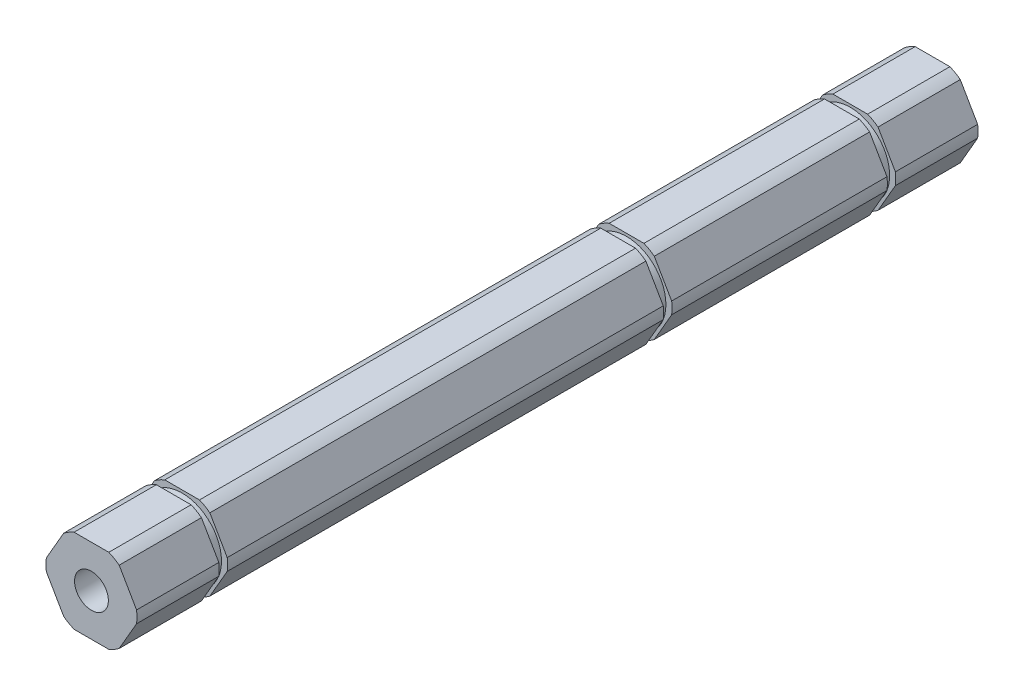
from build123d import *

# Parameters (mm, degrees)
BOSS_EXTRUDE1_DEPTH            = 32.512
SKETCH2_R                      = 5.9436
BOSS_EXTRUDE2_DEPTH            = 1.27
SKETCH3_R                      = 5.9436
BOSS_EXTRUDE3_DEPTH            = 1.27
BOSS_EXTRUDE4_DEPTH            = 65.8368
BOSS_EXTRUDE5_DEPTH            = 12.4206
SKETCH6_R                      = 5.9436
BOSS_EXTRUDE6_DEPTH            = 1.27
BOSS_EXTRUDE7_DEPTH            = 12.4206
F_7_0_201_DIAMETER_HOLE1_D     = 5.1054
F_7_0_201_DIAMETER_HOLE1_DEPTH = 127


with BuildPart() as part:
    # Sketch1 → Boss-Extrude1 (new body)
    with BuildSketch(Plane.XY.offset(-17.2974)):
        with BuildLine():
            Line((-4.187390656, 5.447226632), (-6.811131972, 0.902773368))
            ThreePointArc((-6.811131972, 0.902773368), (-6.8707, 0), (-6.811131972, -0.902773368))
            Line((-6.811131972, -0.902773368), (-4.187390656, -5.447226632))
            ThreePointArc((-4.187390656, -5.447226632), (-3.43535, -5.950200742), (-2.623741315, -6.35))
            Line((-2.623741315, -6.35), (2.623741315, -6.35))
            ThreePointArc((2.623741315, -6.35), (3.43535, -5.950200742), (4.187390656, -5.447226632))
            Line((4.187390656, -5.447226632), (6.811131972, -0.902773368))
            ThreePointArc((6.811131972, -0.902773368), (6.8707, 0), (6.811131972, 0.902773368))
            Line((6.811131972, 0.902773368), (4.187390656, 5.447226632))
            ThreePointArc((4.187390656, 5.447226632), (3.43535, 5.950200742), (2.623741315, 6.35))
            Line((2.623741315, 6.35), (-2.623741315, 6.35))
            ThreePointArc((-2.623741315, 6.35), (-3.43535, 5.950200742), (-4.187390656, 5.447226632))
        make_face()
    extrude(amount=-BOSS_EXTRUDE1_DEPTH)

    # Sketch2 → Boss-Extrude2 (add)
    with BuildSketch(Plane(origin=(0, 0, -49.8094), x_dir=(-1, 0, 0), z_dir=(0, 0, -1))):
        Circle(SKETCH2_R)
    extrude(amount=BOSS_EXTRUDE2_DEPTH)

    # Sketch3 → Boss-Extrude3 (add)
    with BuildSketch(Plane.XY.offset(-17.2974)):
        Circle(SKETCH3_R)
    extrude(amount=BOSS_EXTRUDE3_DEPTH)

    # Sketch4 → Boss-Extrude4 (add)
    with BuildSketch(Plane(origin=(0, 0, -16.0274), x_dir=(-1, 0, 0), z_dir=(0, 0, -1))):
        with BuildLine():
            Line((2.623741315, 6.35), (-2.623741315, 6.35))
            ThreePointArc((-2.623741315, 6.35), (-3.43535, 5.950200742), (-4.187390656, 5.447226632))
            Line((-4.187390656, 5.447226632), (-6.811131972, 0.902773368))
            ThreePointArc((-6.811131972, 0.902773368), (-6.8707, 0), (-6.811131972, -0.902773368))
            Line((-6.811131972, -0.902773368), (-4.187390656, -5.447226632))
            ThreePointArc((-4.187390656, -5.447226632), (-3.43535, -5.950200742), (-2.623741315, -6.35))
            Line((-2.623741315, -6.35), (2.623741315, -6.35))
            ThreePointArc((2.623741315, -6.35), (3.43535, -5.950200742), (4.187390656, -5.447226632))
            Line((4.187390656, -5.447226632), (6.811131972, -0.902773368))
            ThreePointArc((6.811131972, -0.902773368), (6.8707, 0), (6.811131972, 0.902773368))
            Line((6.811131972, 0.902773368), (4.187390656, 5.447226632))
            ThreePointArc((4.187390656, 5.447226632), (3.43535, 5.950200742), (2.623741315, 6.35))
        make_face()
    extrude(amount=-BOSS_EXTRUDE4_DEPTH)

    # Sketch5 → Boss-Extrude5 (add)
    with BuildSketch(Plane.XY.offset(-51.0794)):
        with BuildLine():
            Line((-4.187390656, 5.447226632), (-6.811131972, 0.902773368))
            ThreePointArc((-6.811131972, 0.902773368), (-6.8707, 0), (-6.811131972, -0.902773368))
            Line((-6.811131972, -0.902773368), (-4.187390656, -5.447226632))
            ThreePointArc((-4.187390656, -5.447226632), (-3.43535, -5.950200742), (-2.623741315, -6.35))
            Line((-2.623741315, -6.35), (2.623741315, -6.35))
            ThreePointArc((2.623741315, -6.35), (3.43535, -5.950200742), (4.187390656, -5.447226632))
            Line((4.187390656, -5.447226632), (6.811131972, -0.902773368))
            ThreePointArc((6.811131972, -0.902773368), (6.8707, 0), (6.811131972, 0.902773368))
            Line((6.811131972, 0.902773368), (4.187390656, 5.447226632))
            ThreePointArc((4.187390656, 5.447226632), (3.43535, 5.950200742), (2.623741315, 6.35))
            Line((2.623741315, 6.35), (-2.623741315, 6.35))
            ThreePointArc((-2.623741315, 6.35), (-3.43535, 5.950200742), (-4.187390656, 5.447226632))
        make_face()
    extrude(amount=-BOSS_EXTRUDE5_DEPTH)

    # Sketch6 → Boss-Extrude6 (add)
    with BuildSketch(Plane.XY.offset(49.8094)):
        Circle(SKETCH6_R)
    extrude(amount=BOSS_EXTRUDE6_DEPTH)

    # Sketch7 → Boss-Extrude7 (add)
    with BuildSketch(Plane(origin=(0, 0, 51.0794), x_dir=(-1, 0, 0), z_dir=(0, 0, -1))):
        with BuildLine():
            Line((6.811131972, 0.902773368), (4.187390656, 5.447226632))
            ThreePointArc((4.187390656, 5.447226632), (3.43535, 5.950200742), (2.623741315, 6.35))
            Line((2.623741315, 6.35), (-2.623741315, 6.35))
            ThreePointArc((-2.623741315, 6.35), (-3.43535, 5.950200742), (-4.187390656, 5.447226632))
            Line((-4.187390656, 5.447226632), (-6.811131972, 0.902773368))
            ThreePointArc((-6.811131972, 0.902773368), (-6.8707, 0), (-6.811131972, -0.902773368))
            Line((-6.811131972, -0.902773368), (-4.187390656, -5.447226632))
            ThreePointArc((-4.187390656, -5.447226632), (-3.43535, -5.950200742), (-2.623741315, -6.35))
            Line((-2.623741315, -6.35), (2.623741315, -6.35))
            ThreePointArc((2.623741315, -6.35), (3.43535, -5.950200742), (4.187390656, -5.447226632))
            Line((4.187390656, -5.447226632), (6.811131972, -0.902773368))
            ThreePointArc((6.811131972, -0.902773368), (6.8707, 0), (6.811131972, 0.902773368))
        make_face()
    extrude(amount=-BOSS_EXTRUDE7_DEPTH)

    # #7 (0.201) Diameter Hole1
    with Locations(Plane(origin=(0, 0, -63.5), x_dir=(-1, 0, 0), z_dir=(0, 0, -1))):
        with Locations((0, 0)):
            Hole(F_7_0_201_DIAMETER_HOLE1_D / 2, depth=F_7_0_201_DIAMETER_HOLE1_DEPTH)


solid = part.part
